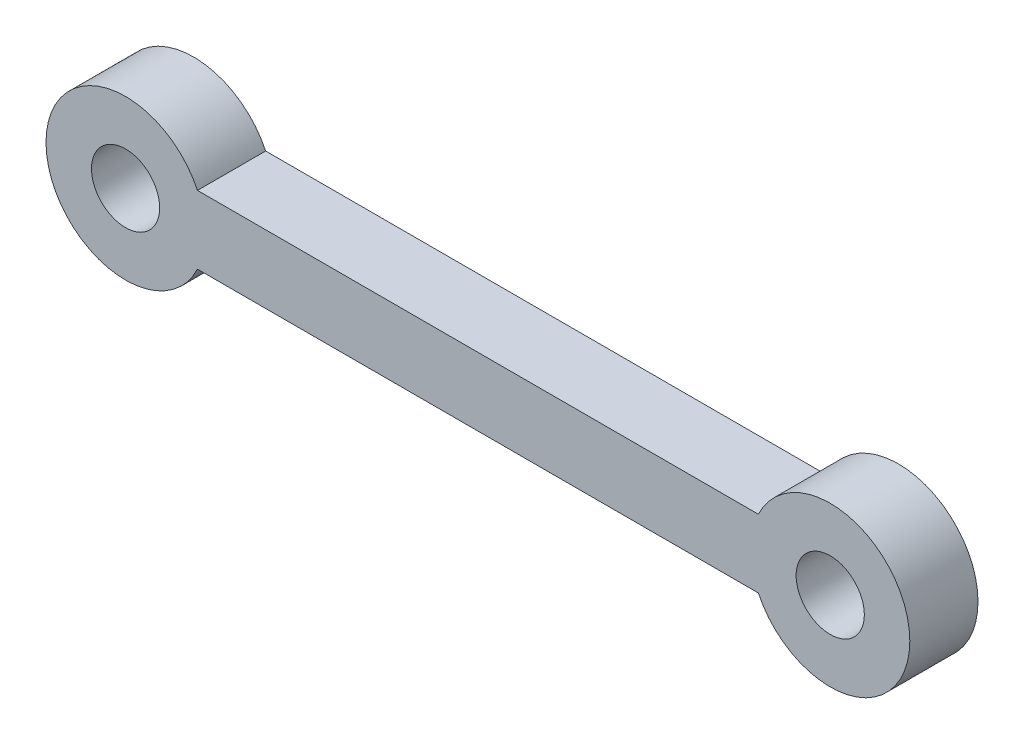
from build123d import *

# Parameters (mm, degrees)
SKETCH_1_R      = 1.5
EXTRUDE_1_DEPTH = 3


with BuildPart() as part:
    # 草图1 → 凸台-拉伸1 (new body)
    with BuildSketch(Plane.XY):
        with BuildLine():
            ThreePointArc((3.16227766, 1.5), (-3.5, 0), (3.16227766, -1.5))
            Line((3.16227766, -1.5), (3.16227766, 1.5))
        make_face()
        Circle(SKETCH_1_R, mode=Mode.SUBTRACT)
        with BuildLine():
            ThreePointArc((3.5, 0), (3.414525722, -0.768774411), (3.16227766, -1.5))
            Line((3.16227766, -1.5), (27.83772234, -1.5))
            ThreePointArc((27.83772234, -1.5), (27.5, 0), (27.83772234, 1.5))
            Line((27.83772234, 1.5), (3.16227766, 1.5))
            ThreePointArc((3.16227766, 1.5), (3.414525722, 0.768774411), (3.5, 0))
        make_face()
        with BuildLine():
            Line((27.83772234, 1.5), (27.83772234, -1.5))
            ThreePointArc((27.83772234, -1.5), (31.768774411, -3.414525722), (34.5, 0))
            ThreePointArc((34.5, 0), (31.768774411, 3.414525722), (27.83772234, 1.5))
        make_face()
        with Locations((31, 0)):
            Circle(SKETCH_1_R, mode=Mode.SUBTRACT)
        with BuildLine():
            Line((3.16227766, 1.5), (3.16227766, -1.5))
            ThreePointArc((3.16227766, -1.5), (3.414525722, -0.768774411), (3.5, 0))
            ThreePointArc((3.5, 0), (3.414525722, 0.768774411), (3.16227766, 1.5))
        make_face()
        with BuildLine():
            ThreePointArc((27.83772234, 1.5), (27.5, 0), (27.83772234, -1.5))
            Line((27.83772234, -1.5), (27.83772234, 1.5))
        make_face()
    extrude(amount=EXTRUDE_1_DEPTH)


solid = part.part
